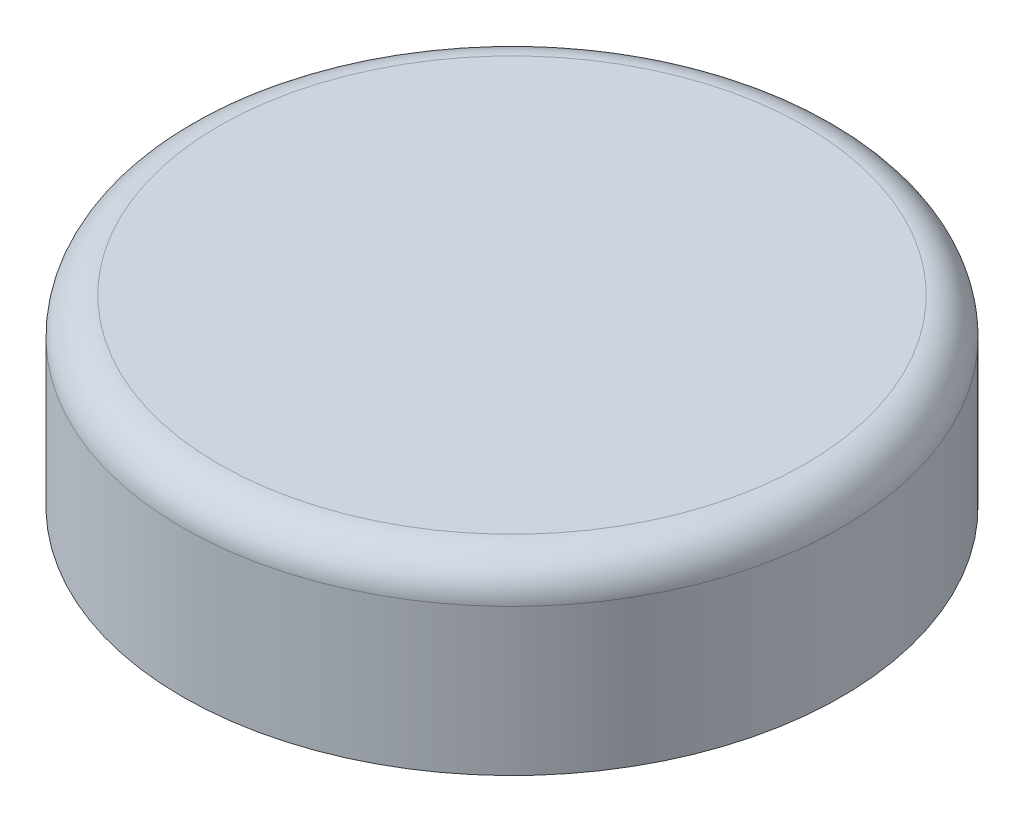
from build123d import *

# Parameters (mm, degrees)
ESQUISSE1_R        = 9
BOSS_EXTRU_1_DEPTH = 5
CONG_1_R           = 1


with BuildPart() as part:
    # Esquisse1 → Boss.-Extru.1 (new body)
    with BuildSketch(Plane(origin=(0, 0, 0), x_dir=(1, 0, 0), z_dir=(0, 1, 0))):
        Circle(ESQUISSE1_R)
    extrude(amount=BOSS_EXTRU_1_DEPTH)

    # Congé1
    cong_1_edges = [part.edges().sort_by_distance(p)[0] for p in [
        (-9, 5, 0),
    ]]
    fillet(cong_1_edges, radius=CONG_1_R)


solid = part.part
